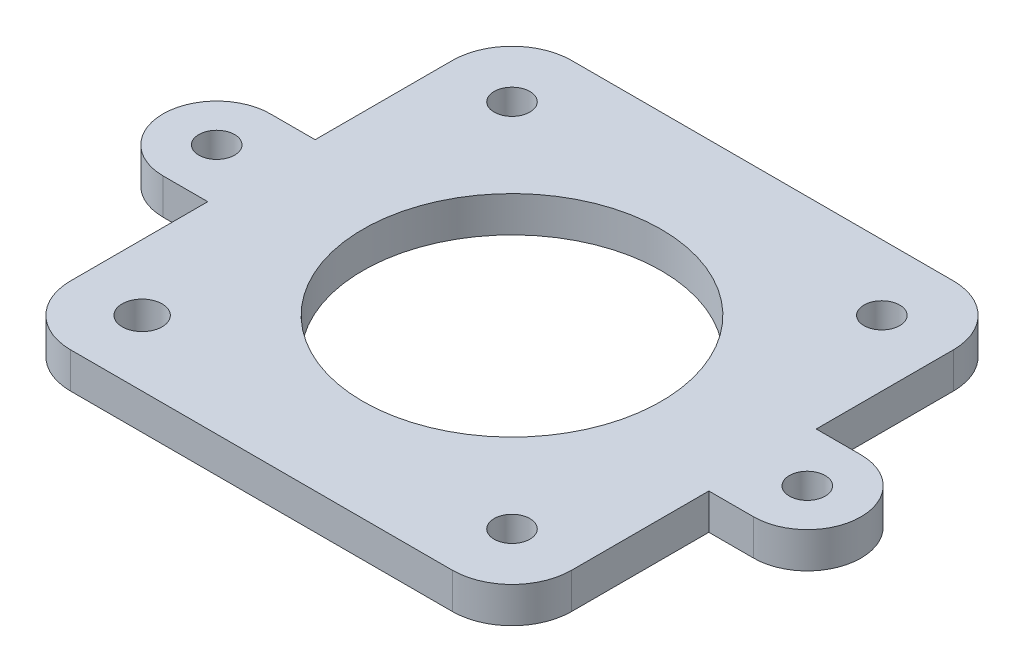
from build123d import *

# Parameters (mm, degrees)
SKETCH1_R           = 1.5
SKETCH1_R_2         = 1.672925925
BOSS_EXTRUDE1_DEPTH = 3
SKETCH2_R           = 12.5
CUT_EXTRUDE1_DEPTH  = 4
SKETCH3_R           = 1.5
BOSS_EXTRUDE2_DEPTH = 3


with BuildPart() as part:
    # Sketch1 → Boss-Extrude1 (new body)
    with BuildSketch(Plane(origin=(0, 0, 0), x_dir=(1, 0, 0), z_dir=(0, 1, 0))):
        with BuildLine():
            Line((-16, -21), (16, -21))
            ThreePointArc((16, -21), (19.535533906, -19.535533906), (21, -16))
            Line((21, -16), (21, 16))
            ThreePointArc((21, 16), (19.535533906, 19.535533906), (16, 21))
            Line((16, 21), (-16, 21))
            ThreePointArc((-16, 21), (-19.535533906, 19.535533906), (-21, 16))
            Line((-21, 16), (-21, -16))
            ThreePointArc((-21, -16), (-19.535533906, -19.535533906), (-16, -21))
        make_face()
        with Locations((15.5, 15.5)):
            Circle(SKETCH1_R, mode=Mode.SUBTRACT)
        with Locations((15.5, -15.5)):
            Circle(SKETCH1_R, mode=Mode.SUBTRACT)
        with Locations((-15.5, 15.5)):
            Circle(SKETCH1_R, mode=Mode.SUBTRACT)
        with Locations((-15.5, -15.5)):
            Circle(SKETCH1_R_2, mode=Mode.SUBTRACT)
    extrude(amount=BOSS_EXTRUDE1_DEPTH)

    # Sketch2 → Cut-Extrude1 (cut, through all)
    with BuildSketch(Plane(origin=(0, 3, 0), x_dir=(1, 0, 0), z_dir=(0, 1, 0))):
        Circle(SKETCH2_R)
    extrude(amount=-CUT_EXTRUDE1_DEPTH, mode=Mode.SUBTRACT)

    # Sketch3 → Boss-Extrude2 (add)
    with BuildSketch(Plane(origin=(0, 3, 0), x_dir=(1, 0, 0), z_dir=(0, 1, 0))):
        with BuildLine():
            Line((-24.75, 4.5), (-21, 4.5))
            Line((-21, 4.5), (-21, -4.5))
            Line((-21, -4.5), (-24.75, -4.5))
            ThreePointArc((-24.75, -4.5), (-29.25, 0), (-24.75, 4.5))
        make_face()
        with Locations((-24.75, 0)):
            Circle(SKETCH3_R, mode=Mode.SUBTRACT)
        with BuildLine():
            Line((24.75, -4.5), (21, -4.5))
            Line((21, -4.5), (21, 4.5))
            Line((21, 4.5), (24.75, 4.5))
            ThreePointArc((24.75, 4.5), (29.25, 0), (24.75, -4.5))
        make_face()
        with Locations((24.75, 0)):
            Circle(SKETCH3_R, mode=Mode.SUBTRACT)
    extrude(amount=-BOSS_EXTRUDE2_DEPTH)


solid = part.part
